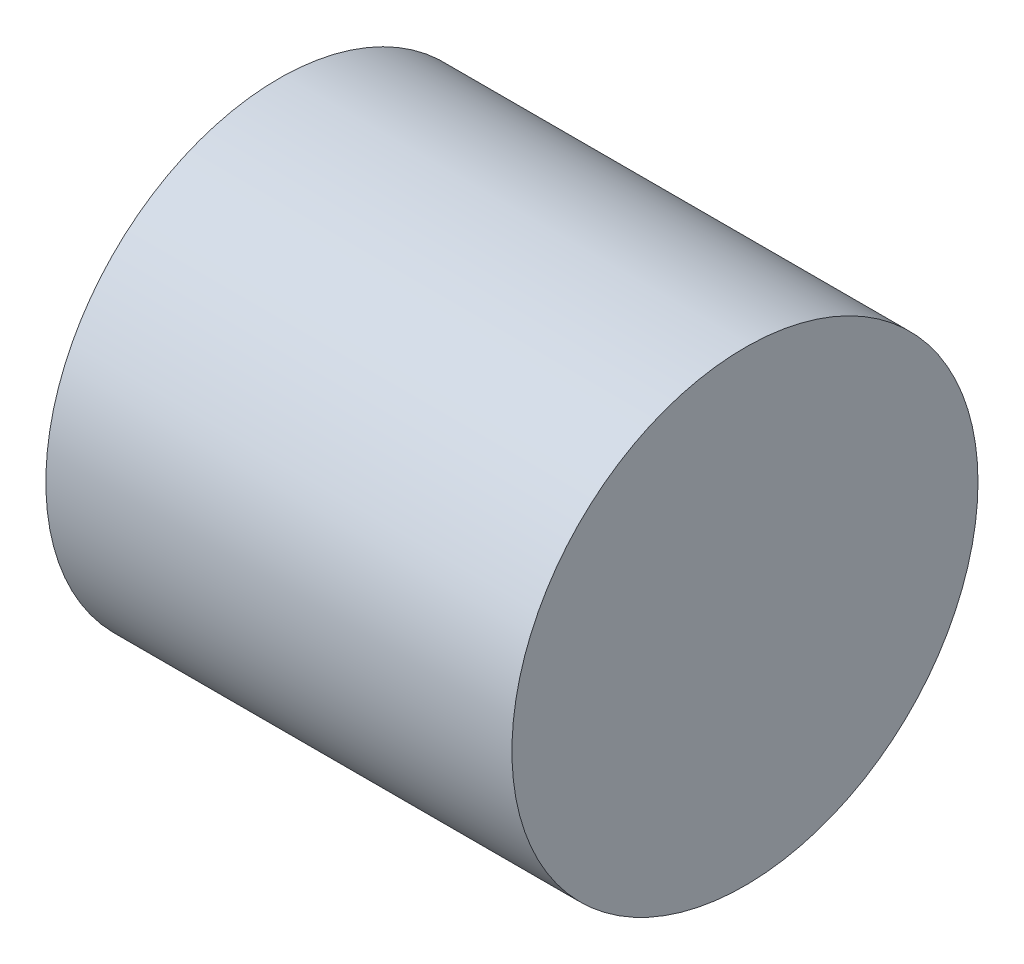
from build123d import *

# Parameters (mm, degrees)
ESQUISSE1_R        = 5
BOSS_EXTRU_1_DEPTH = 10


with BuildPart() as part:
    # Esquisse1 → Boss.-Extru.1 (new body)
    with BuildSketch(Plane(origin=(0, 0, 0), x_dir=(0, 0, -1), z_dir=(1, 0, 0))):
        Circle(ESQUISSE1_R)
    extrude(amount=BOSS_EXTRU_1_DEPTH)


solid = part.part
